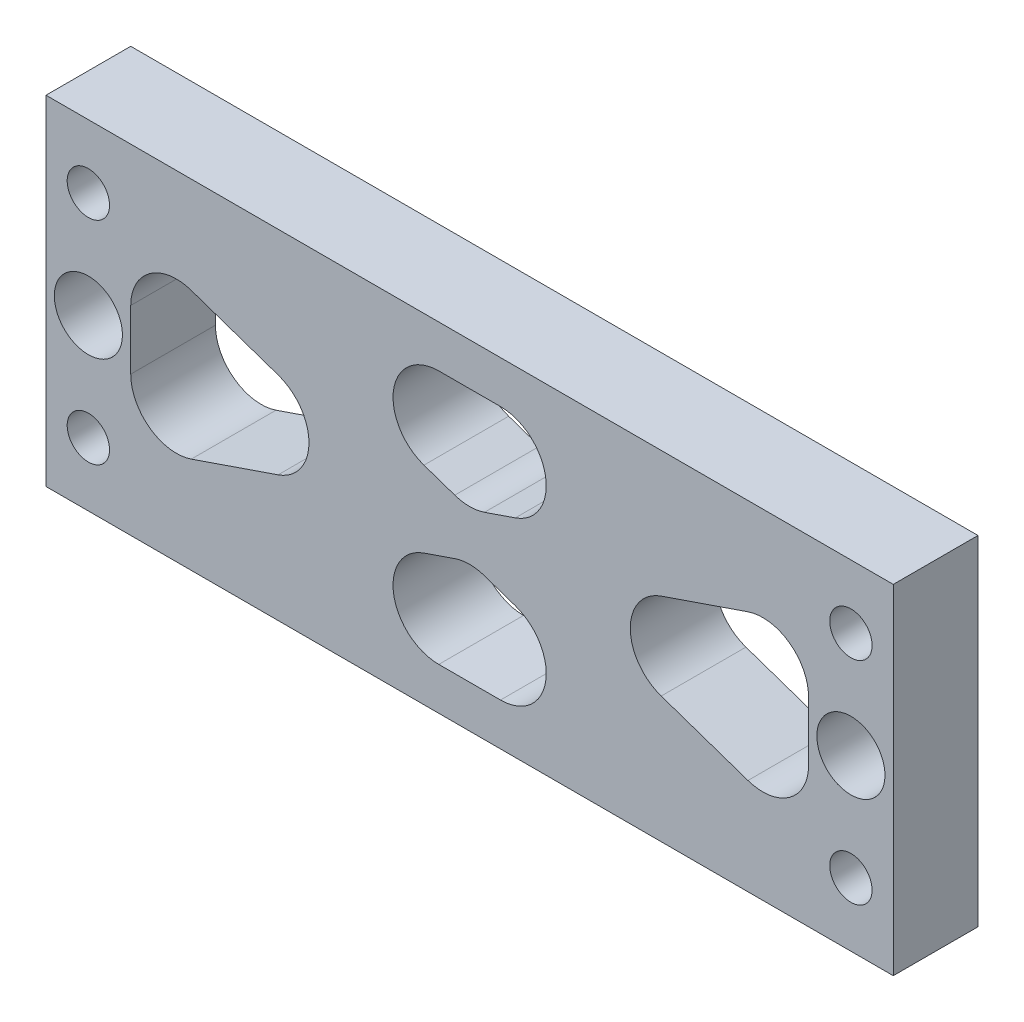
from build123d import *

# Parameters (mm, degrees)
SKETCH1_W                              = 63.5
SKETCH1_H                              = 25.4
BOSS_EXTRUDE1_DEPTH                    = 6.35
F_10_CLEARANCE_HOLE1_D                 = 5.1054
F_1_8_0_125_TRANSITIONAL_DOWEL_HOLE1_D = 3.175
CUT_EXTRUDE1_DEPTH                     = 7.35
FILLET1_R                              = 3.429


with BuildPart() as part:
    # Sketch1 → Boss-Extrude1 (new body)
    with BuildSketch(Plane.XY):
        Rectangle(SKETCH1_W, SKETCH1_H)
    extrude(amount=BOSS_EXTRUDE1_DEPTH)

    # #10 Clearance Hole1 (through all)
    with Locations(Plane.XY.offset(6.35)):
        with Locations((-28.575, 0), (28.575, 0)):
            Hole(F_10_CLEARANCE_HOLE1_D / 2)

    # 1/8 (0.125) Transitional Dowel Hole1 (through all)
    with Locations(Plane.XY.offset(6.35)):
        with Locations((-28.575, 7.9375), (-28.575, -7.9375), (28.575, 7.9375), (28.575, -7.9375)):
            Hole(F_1_8_0_125_TRANSITIONAL_DOWEL_HOLE1_D / 2)

    # Sketch6 → Cut-Extrude1 (cut, through all)
    with BuildSketch(Plane.XY.offset(6.35)):
        Polygon((-25.4, 7.0296834), (-4.895137561, 0), (-25.4, -7.0296834), align=None)
        Polygon((-22.888306389, 9.525), (0, 1.678200347), (22.888306389, 9.525), align=None)
        Polygon((25.4, 7.0296834), (4.895137561, 0), (25.4, -7.0296834), align=None)
        Polygon((22.888306389, -9.525), (0, -1.678200347), (-22.888306389, -9.525), align=None)
    extrude(amount=-CUT_EXTRUDE1_DEPTH, mode=Mode.SUBTRACT)

    # Fillet1
    fillet1_edges = [part.edges().sort_by_distance(p)[0] for p in [
        (-25.4, -7.0296834, 3.175),
        (-25.4, 7.0296834, 3.175),
        (-4.895137561, 0, 3.175),
        (25.4, 7.0296834, 3.175),
        (25.4, -7.0296834, 3.175),
        (4.895137561, 0, 3.175),
        (22.888306389, -9.525, 3.175),
        (-22.888306389, -9.525, 3.175),
        (0, -1.678200347, 3.175),
        (-22.888306389, 9.525, 3.175),
        (22.888306389, 9.525, 3.175),
        (0, 1.678200347, 3.175),
    ]]
    fillet(fillet1_edges, radius=FILLET1_R)


solid = part.part
